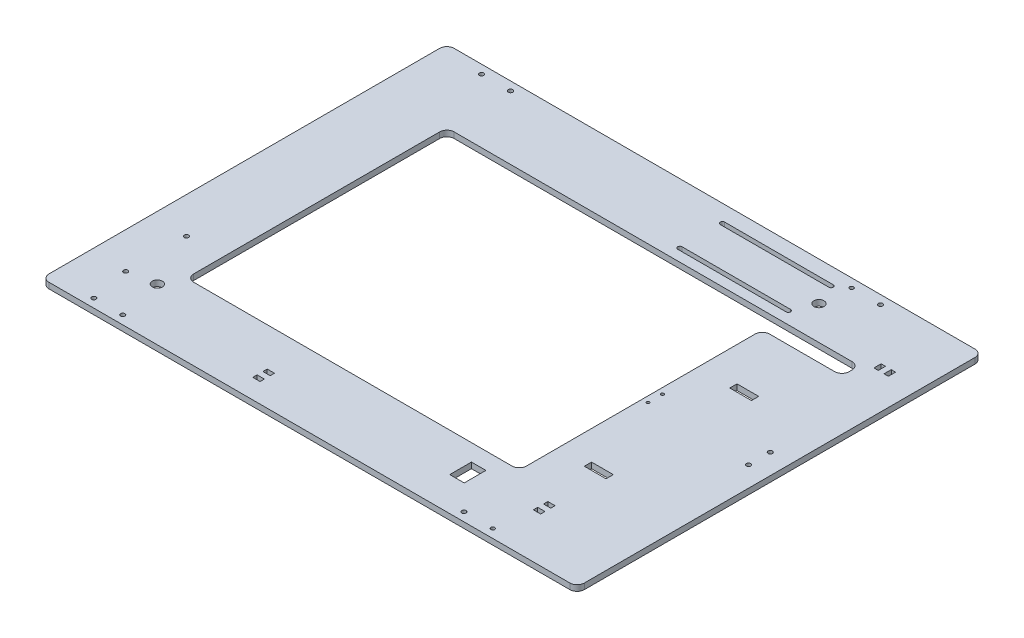
from build123d import *

# Parameters (mm, degrees)
SKETCH1_W           = 370
SKETCH1_H           = 280
SKETCH1_R           = 1.5
SKETCH1_R_2         = 1.569181713
SKETCH1_R_3         = 1.357318829
SKETCH1_R_4         = 1.322467774
SKETCH1_R_5         = 1
SKETCH1_W_2         = 230
SKETCH1_H_2         = 180
BOSS_EXTRUDE1_DEPTH = 4
SKETCH2_W           = 55
SKETCH2_H           = 12
CUT_EXTRUDE1_DEPTH  = 10
SKETCH3_R           = 1.5
CUT_EXTRUDE2_DEPTH  = 10
CUT_EXTRUDE3_DEPTH  = 10
FILLET3_R           = 5
FILLET4_R           = 5
FILLET5_R           = 5
FILLET6_R           = 5
FILLET7_R           = 5
FILLET8_R           = 5
FILLET9_R           = 5
SKETCH6_R           = 3.5
CUT_EXTRUDE4_DEPTH  = 10
SKETCH7_R           = 3.5
CUT_EXTRUDE5_DEPTH  = 10
SKETCH8_W           = 5
SKETCH8_H           = 3
SKETCH8_W_2         = 10
SKETCH8_H_2         = 15
SKETCH8_W_3         = 15
SKETCH8_H_3         = 5
SKETCH8_W_4         = 3
CUT_EXTRUDE6_DEPTH  = 10
SKETCH9_R           = 1.5
CUT_EXTRUDE7_DEPTH  = 10


with BuildPart() as part:
    # Sketch1 → Boss-Extrude1 (new body)
    with BuildSketch(Plane(origin=(0, 0, 0), x_dir=(1, 0, 0), z_dir=(0, 1, 0))):
        with Locations((185, 140)):
            Rectangle(SKETCH1_W, SKETCH1_H)
        with Locations((30, 274)):
            Circle(SKETCH1_R, mode=Mode.SUBTRACT)
        with Locations((50, 274)):
            Circle(SKETCH1_R_2, mode=Mode.SUBTRACT)
        with Locations((30, 6)):
            Circle(SKETCH1_R, mode=Mode.SUBTRACT)
        with Locations((50, 6)):
            Circle(SKETCH1_R, mode=Mode.SUBTRACT)
        with Locations((285.756924446, 273.985388104)):
            Circle(SKETCH1_R_3, mode=Mode.SUBTRACT)
        with Locations((305.756860025, 273.934625414)):
            Circle(SKETCH1_R, mode=Mode.SUBTRACT)
        with Locations((285.756860726, 6.001523901)):
            Circle(SKETCH1_R, mode=Mode.SUBTRACT)
        with Locations((305.756860025, 6.006818111)):
            Circle(SKETCH1_R_4, mode=Mode.SUBTRACT)
        with Locations((284, 145)):
            Circle(SKETCH1_R_5, mode=Mode.SUBTRACT)
        with Locations((284, 135)):
            Circle(SKETCH1_R_5, mode=Mode.SUBTRACT)
        with Locations((165, 140)):
            Rectangle(SKETCH1_W_2, SKETCH1_H_2, mode=Mode.SUBTRACT)
    extrude(amount=BOSS_EXTRUDE1_DEPTH)

    # Sketch2 → Cut-Extrude1 (cut)
    with BuildSketch(Plane(origin=(0, 4, 0), x_dir=(1, 0, 0), z_dir=(0, 1, 0))):
        with Locations((307.5, 224)):
            Rectangle(SKETCH2_W, SKETCH2_H)
    extrude(amount=-CUT_EXTRUDE1_DEPTH, mode=Mode.SUBTRACT)

    # Sketch3 → Cut-Extrude2 (cut)
    with BuildSketch(Plane(origin=(0, 4, 0), x_dir=(1, 0, 0), z_dir=(0, 1, 0))):
        with Locations((356, 147.5)):
            Circle(SKETCH3_R)
        with Locations((356, 132.5)):
            Circle(SKETCH3_R)
    extrude(amount=-CUT_EXTRUDE2_DEPTH, mode=Mode.SUBTRACT)

    # Sketch4 → Cut-Extrude3 (cut)
    with BuildSketch(Plane(origin=(0, 4, 0), x_dir=(1, 0, 0), z_dir=(0, 1, 0))):
        with BuildLine():
            Line((277.5, 266.5), (202.5, 266.5))
            ThreePointArc((202.5, 266.5), (201, 268), (202.5, 269.5))
            Line((202.5, 269.5), (277.5, 269.5))
            ThreePointArc((277.5, 269.5), (279, 268), (277.5, 266.5))
        make_face()
        with BuildLine():
            Line((277.5, 237), (202.5, 237))
            ThreePointArc((202.5, 237), (201, 238.5), (202.5, 240))
            Line((202.5, 240), (277.5, 240))
            ThreePointArc((277.5, 240), (279, 238.5), (277.5, 237))
        make_face()
    extrude(amount=-CUT_EXTRUDE3_DEPTH, mode=Mode.SUBTRACT)

    # Fillet3
    fillet3_edges = [part.edges().sort_by_distance(p)[0] for p in [
        (370, 2, 0),
    ]]
    fillet(fillet3_edges, radius=FILLET3_R)

    # Fillet4
    fillet4_edges = [part.edges().sort_by_distance(p)[0] for p in [
        (370, 2, -280),
    ]]
    fillet(fillet4_edges, radius=FILLET4_R)

    # Fillet5
    fillet5_edges = [part.edges().sort_by_distance(p)[0] for p in [
        (0, 2, 0),
    ]]
    fillet(fillet5_edges, radius=FILLET5_R)

    # Fillet6
    fillet6_edges = [part.edges().sort_by_distance(p)[0] for p in [
        (0, 2, -280),
    ]]
    fillet(fillet6_edges, radius=FILLET6_R)

    # Fillet7
    fillet7_edges = [part.edges().sort_by_distance(p)[0] for p in [
        (280, 2, -218),
    ]]
    fillet(fillet7_edges, radius=FILLET7_R)

    # Fillet8
    fillet8_edges = [part.edges().sort_by_distance(p)[0] for p in [
        (280, 2, -50),
    ]]
    fillet(fillet8_edges, radius=FILLET8_R)

    # Fillet9
    fillet9_edges = [part.edges().sort_by_distance(p)[0] for p in [
        (50, 2, -230),
        (50, 2, -50),
        (335, 2, -230),
        (335, 2, -218),
    ]]
    fillet(fillet9_edges, radius=FILLET9_R)

    # Sketch6 → Cut-Extrude4 (cut)
    with BuildSketch(Plane.XZ):
        with Locations((283.852252581, -253.25)):
            Circle(SKETCH6_R)
    extrude(amount=-CUT_EXTRUDE4_DEPTH, mode=Mode.SUBTRACT)

    # Sketch7 → Cut-Extrude5 (cut)
    with BuildSketch(Plane.XZ):
        with Locations((43.528330195, -36.357190156)):
            Circle(SKETCH7_R)
    extrude(amount=-CUT_EXTRUDE5_DEPTH, mode=Mode.SUBTRACT)

    # Sketch8 → Cut-Extrude6 (cut)
    with BuildSketch(Plane.XZ):
        with Locations((134.85877855, -14.984967273)):
            Rectangle(SKETCH8_W, SKETCH8_H)
        with Locations((134.85877855, -21.984967273)):
            Rectangle(SKETCH8_W, SKETCH8_H)
        with Locations((263.601107072, -30.863134191)):
            Rectangle(SKETCH8_W_2, SKETCH8_H_2)
        with Locations((311.102535039, -32.659137944)):
            Rectangle(SKETCH8_W, SKETCH8_H)
        with Locations((311.102535039, -39.659137944)):
            Rectangle(SKETCH8_W, SKETCH8_H)
        with Locations((307.626119627, -77.359497152)):
            Rectangle(SKETCH8_W_3, SKETCH8_H_3)
        with Locations((342.859262651, -236.259221691)):
            Rectangle(SKETCH8_W_4, SKETCH8_H_3)
        with Locations((349.859262651, -236.259221691)):
            Rectangle(SKETCH8_W_4, SKETCH8_H_3)
        with Locations((311.053880499, -174.438404524)):
            Rectangle(SKETCH8_W_3, SKETCH8_H_3)
    extrude(amount=-CUT_EXTRUDE6_DEPTH, mode=Mode.SUBTRACT)

    # Sketch9 → Cut-Extrude7 (cut)
    with BuildSketch(Plane.XZ):
        with Locations((25, -33)):
            Circle(SKETCH9_R)
        with Locations((25, -75)):
            Circle(SKETCH9_R)
    extrude(amount=-CUT_EXTRUDE7_DEPTH, mode=Mode.SUBTRACT)


solid = part.part
